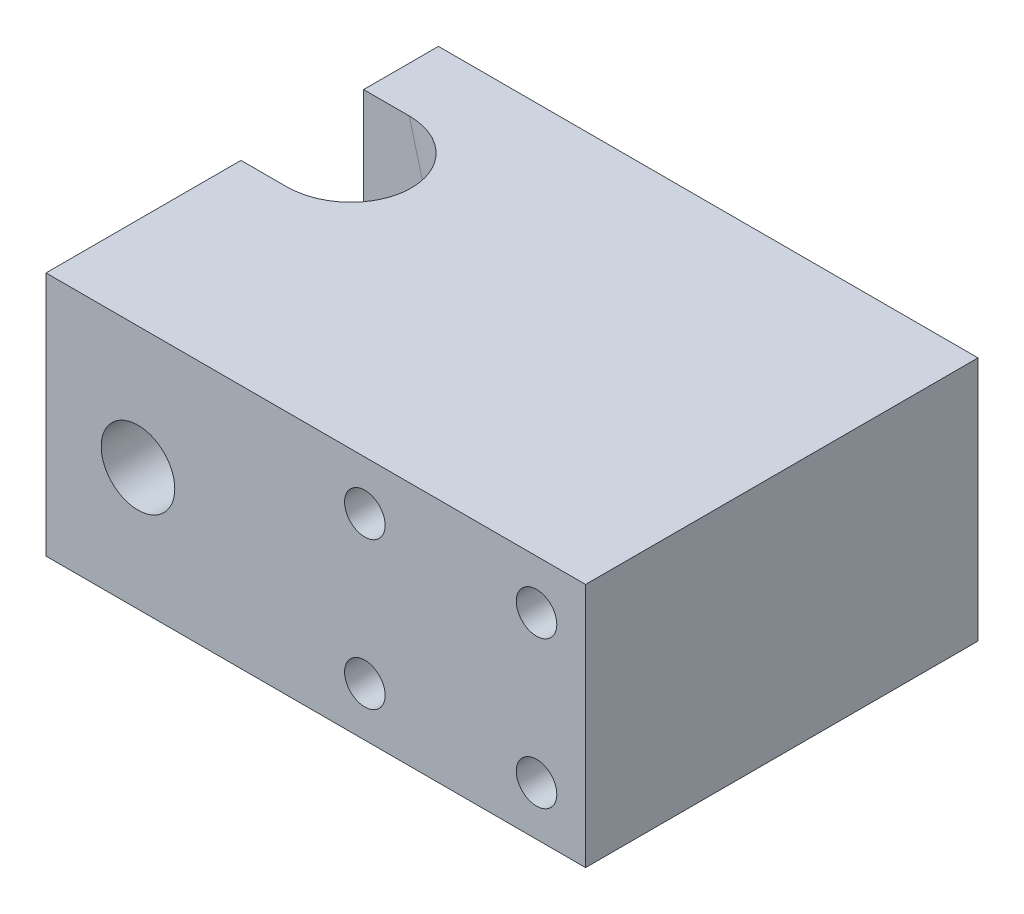
from build123d import *

# Parameters (mm, degrees)
SKETCH1_W                 = 55.88
SKETCH1_H                 = 40.64
BOSS_EXTRUDE1_DEPTH       = 25.4
SKETCH3_R                 = 3.81
CUT_EXTRUDE1_DEPTH        = 74.616193871
M5X0_8_TAPPED_HOLE1_D     = 4.2
M5X0_8_TAPPED_HOLE1_DEPTH = 25.4
M5X0_8_TAPPED_HOLE1_TIP   = 1.2618073
CUT_EXTRUDE3_DEPTH        = 73.924463946
CUT_EXTRUDE3_DEPTH_BACK   = 73.924463946


with BuildPart() as part:
    # Sketch1 → Boss-Extrude1 (new body)
    with BuildSketch(Plane(origin=(0, 0, 0), x_dir=(1, 0, 0), z_dir=(0, 1, 0))):
        with Locations((27.94, 20.32)):
            Rectangle(SKETCH1_W, SKETCH1_H)
    extrude(amount=BOSS_EXTRUDE1_DEPTH)

    # Sketch3 → Cut-Extrude1 (cut, through all)
    with BuildSketch(Plane.XY):
        with Locations((9.525, 12.7)):
            Circle(SKETCH3_R)
    extrude(amount=-CUT_EXTRUDE1_DEPTH, mode=Mode.SUBTRACT)

    # M5x0.8 Tapped Hole1
    with Locations(Plane.XY):
        with Locations((50.8, 5.08), (33.02, 5.08), (33.02, 20.32), (50.8, 20.32)):
            Hole(M5X0_8_TAPPED_HOLE1_D / 2, depth=M5X0_8_TAPPED_HOLE1_DEPTH)
            with Locations((0, 0, -(M5X0_8_TAPPED_HOLE1_DEPTH + M5X0_8_TAPPED_HOLE1_TIP / 2))):  # 118° drill point
                Cone(0, M5X0_8_TAPPED_HOLE1_D / 2, M5X0_8_TAPPED_HOLE1_TIP, mode=Mode.SUBTRACT)

    # Sketch8 → Cut-Extrude3 (cut, two sides: drawn at the far end of the back side and taken through both)
    with BuildSketch(Plane(origin=(-2.536945986, 9.468011314, 0), x_dir=(0.9659258262890681, 0.25881904510252135, 0), z_dir=(-0.25881904510252135, 0.9659258262890681, 0)).offset(-CUT_EXTRUDE3_DEPTH_BACK)):
        with BuildLine():
            Line((0, 20.19), (11.137445368, 20.19))
            ThreePointArc((11.137445368, 20.19), (17.487445368, 26.54), (11.137445368, 32.89))
            Line((11.137445368, 32.89), (0, 32.89))
            Line((0, 32.89), (0, 20.19))
        make_face()
    extrude(amount=CUT_EXTRUDE3_DEPTH + CUT_EXTRUDE3_DEPTH_BACK, mode=Mode.SUBTRACT)


solid = part.part
